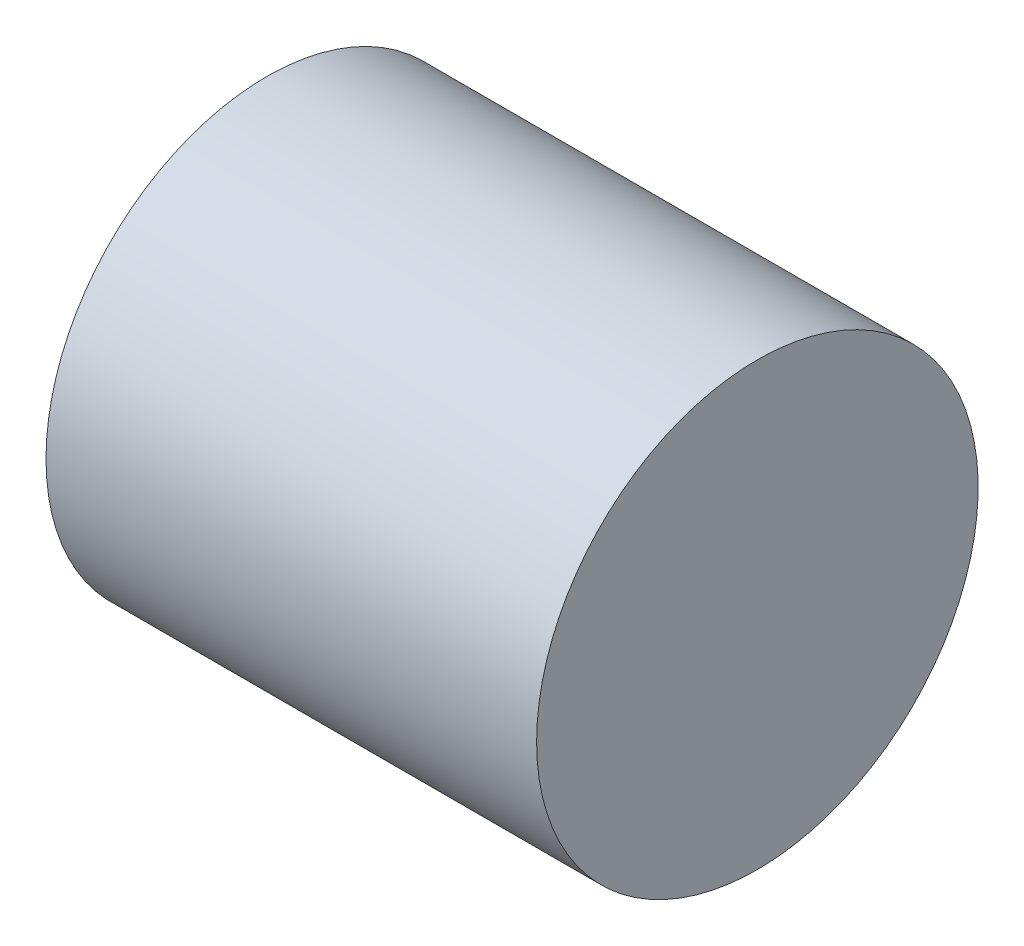
from build123d import *

# Parameters (mm, degrees)
SCHIZZO1_W = 40
SCHIZZO1_H = 18


with BuildPart() as part:
    # Schizzo1 → Rivoluzione1 (revolve)
    with BuildSketch(Plane.XY):
        with Locations((20, 9)):
            Rectangle(SCHIZZO1_W, SCHIZZO1_H)
    revolve(axis=Axis((0, 18, 0), (1, 0, 0)))


solid = part.part
